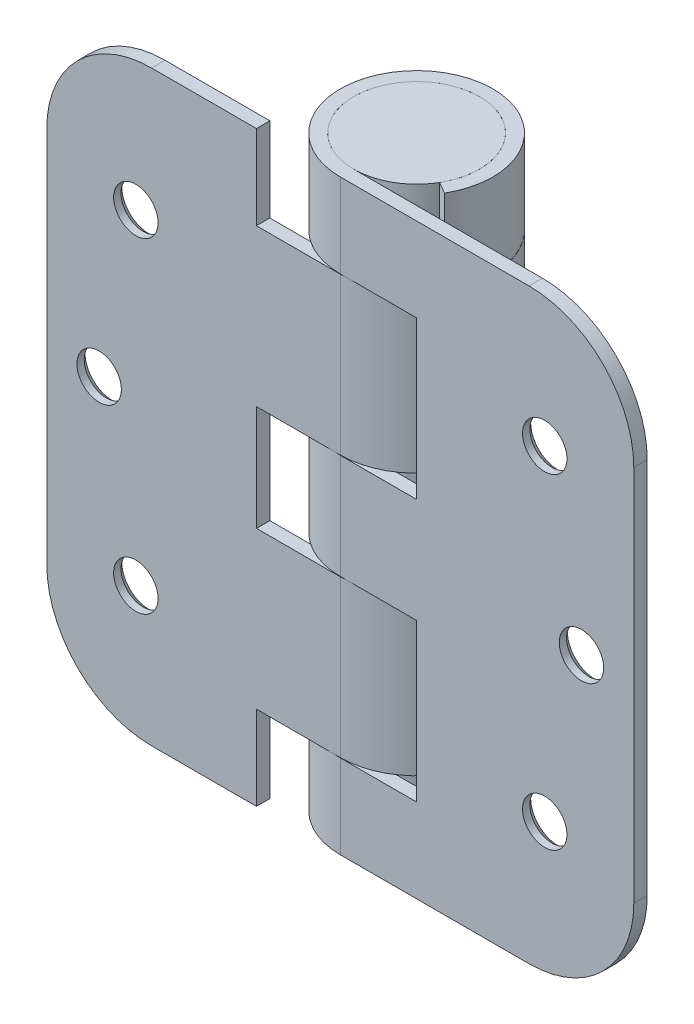
from build123d import *

# Parameters (mm, degrees)
EXTRUDE1_DEPTH                                = 44.45
CUT_EXTRUDE1_DEPTH                            = 22.082
CUT_EXTRUDE1_DEPTH_BACK                       = 3.032
EXTRUDE2_DEPTH                                = 11.85545
EXTRUDE2_DEPTH_BACK                           = 11.85545
EXTRUDE3_DEPTH                                = 11.85545
EXTRUDE3_DEPTH_BACK                           = 11.85545
EXTRUDE4_START                                = -24.60625
SKETCH5_W                                     = 31.75
SKETCH5_H                                     = 2.032
EXTRUDE4_DEPTH                                = 88.9
SKETCH6_W                                     = 9.525
SKETCH6_H                                     = 88.9
CSK_FOR_8_FLAT_HEAD_MACHINE_SCREW2_AT_2_COUNT = 2
CSK_FOR_8_FLAT_HEAD_MACHINE_SCREW2_AT_2_PITCH = 25.258138545
CSK_FOR_8_FLAT_HEAD_MACHINE_SCREW2_AT_3_COUNT = 2
CSK_FOR_8_FLAT_HEAD_MACHINE_SCREW2_AT_3_PITCH = 25.258138545
CSK_FOR_8_FLAT_HEAD_MACHINE_SCREW2_AT_4_COUNT = 2
CSK_FOR_8_FLAT_HEAD_MACHINE_SCREW2_AT_4_PITCH = 71.844514007
CSK_FOR_8_FLAT_HEAD_MACHINE_SCREW2_AT_5_COUNT = 2
CSK_FOR_8_FLAT_HEAD_MACHINE_SCREW2_AT_5_PITCH = 73.0504
CSK_FOR_8_FLAT_HEAD_MACHINE_SCREW2_AT_6_COUNT = 2
CSK_FOR_8_FLAT_HEAD_MACHINE_SCREW2_AT_6_PITCH = 71.844514007
FILLET1_R                                     = 15.875
FILLET2_R                                     = 15.875
FILLET3_R                                     = 15.875
FILLET4_R                                     = 15.875


with BuildPart() as part:
    # Sketch1 → Extrude1 (new body, symmetric)
    with BuildSketch(Plane(origin=(0, 0, 0), x_dir=(1, 0, 0), z_dir=(0, 1, 0))):
        with BuildLine():
            Line((0, -9.525), (44.45, -9.525))
            Line((44.45, -9.525), (44.45, -11.557))
            Line((44.45, -11.557), (0, -11.557))
            ThreePointArc((0, -11.557), (-5.7785, 10.008655592), (10.008655592, -5.7785))
            Line((10.008655592, -5.7785), (8.248891971, -4.7625))
            ThreePointArc((8.248891971, -4.7625), (-4.7625, 8.248891971), (0, -9.525))
        make_face()
    extrude(amount=EXTRUDE1_DEPTH, both=True)

    # Sketch2 → Cut-Extrude1 (cut, two sides)
    with BuildSketch(Plane(origin=(0, 0, 9.525), x_dir=(-1, 0, 0), z_dir=(0, 0, -1))) as cut_extrude1_sk:
        Polygon((11.557, 264.592751947), (11.557, 44.45), (11.557, 31.75), (-11.557, 31.75), (-11.557, 7.9375), (11.557, 7.9375), (11.557, -7.9375), (-11.557, -7.9375), (-11.557, -31.75), (11.557, -31.75), (11.557, -44.45), (11.557, -264.592751947), (451.842503895, -264.592751947), (451.842503895, 264.592751947), align=None)
    extrude(amount=CUT_EXTRUDE1_DEPTH, mode=Mode.SUBTRACT)
    extrude(cut_extrude1_sk.sketch, amount=-CUT_EXTRUDE1_DEPTH_BACK, mode=Mode.SUBTRACT)


with BuildPart() as body_2:
    # Sketch3 → Extrude2 (new body, two sides)
    with BuildSketch(Plane(origin=(0, 19.84375, 0), x_dir=(-1, 0, 0), z_dir=(0, 1, 0))) as extrude2_sk:
        with BuildLine():
            Line((44.45, 11.557), (44.45, 9.525))
            Line((44.45, 9.525), (0, 9.525))
            ThreePointArc((0, 9.525), (-4.7625, -8.248891971), (8.248891971, 4.7625))
            Line((8.248891971, 4.7625), (10.008655592, 5.7785))
            ThreePointArc((10.008655592, 5.7785), (-5.7785, -10.008655592), (0, 11.557))
            Line((0, 11.557), (44.45, 11.557))
        make_face()
    extrude(amount=EXTRUDE2_DEPTH)
    extrude(extrude2_sk.sketch, amount=-EXTRUDE2_DEPTH_BACK)



with BuildPart() as body_3:
    # Sketch4 → Extrude3 (new body, two sides)
    with BuildSketch(Plane(origin=(0, -19.84375, 0), x_dir=(-1, 0, 0), z_dir=(0, 1, 0))) as extrude3_sk:
        with BuildLine():
            Line((0, 9.525), (44.45, 9.525))
            Line((44.45, 9.525), (44.45, 11.557))
            Line((44.45, 11.557), (0, 11.557))
            ThreePointArc((0, 11.557), (-5.7785, -10.008655592), (10.008655592, 5.7785))
            Line((10.008655592, 5.7785), (8.248891971, 4.7625))
            ThreePointArc((8.248891971, 4.7625), (-4.7625, -8.248891971), (0, 9.525))
        make_face()
    extrude(amount=EXTRUDE3_DEPTH)
    extrude(extrude3_sk.sketch, amount=-EXTRUDE3_DEPTH_BACK)


with BuildPart() as body_2_1:
    add(body_2.part)

    add(body_3.part)  # Extrude4 merges body 3
    # Sketch5 → Extrude4 (add)
    with BuildSketch(Plane(origin=(0, -19.84375, 0), x_dir=(-1, 0, 0), z_dir=(0, 1, 0)).offset(EXTRUDE4_START)):
        with Locations((28.575, 10.541)):
            Rectangle(SKETCH5_W, SKETCH5_H)
    extrude(amount=EXTRUDE4_DEPTH)

    # Sketch9 → CSK for #8 Flat Head Machine Screw2 (revolve, cut)
    with BuildSketch(Plane(origin=(-36.5252, 0, 9.525), x_dir=(0, 1, 0), z_dir=(1, 0, 0))):
        Polygon((0, 0), (0, 4.130193213), (3.3655, 2.1079968), (3.3655, 0.920409763), (4.1656, 0), align=None)
    csk_for_8_flat_head_machine_screw2 = revolve(axis=Axis((-36.5252, 0, 3.175), (0, 0, 1)), mode=Mode.SUBTRACT)

    # CSK for #8 Flat Head Machine Screw2 at 2: CSK for #8 Flat Head Machine Screw2 ×2
    with Locations(*[Vector(0.220230006, 0.975447971, 0) * (i * CSK_FOR_8_FLAT_HEAD_MACHINE_SCREW2_AT_2_PITCH) for i in range(1, CSK_FOR_8_FLAT_HEAD_MACHINE_SCREW2_AT_2_COUNT)]):
        add(csk_for_8_flat_head_machine_screw2, mode=Mode.SUBTRACT)

    # CSK for #8 Flat Head Machine Screw2 at 3: CSK for #8 Flat Head Machine Screw2 ×2
    with Locations(*[Vector(0.220230006, -0.975447971, 0) * (i * CSK_FOR_8_FLAT_HEAD_MACHINE_SCREW2_AT_3_PITCH) for i in range(1, CSK_FOR_8_FLAT_HEAD_MACHINE_SCREW2_AT_3_COUNT)]):
        add(csk_for_8_flat_head_machine_screw2, mode=Mode.SUBTRACT)

    # Fillet3
    fillet3_edges = [body_2_1.edges().sort_by_distance(p)[0] for p in [
        (-44.45, 44.45, 10.541),
    ]]
    fillet(fillet3_edges, radius=FILLET3_R)

    # Fillet4
    fillet4_edges = [body_2_1.edges().sort_by_distance(p)[0] for p in [
        (-44.45, -44.45, 10.541),
    ]]
    fillet(fillet4_edges, radius=FILLET4_R)


with BuildPart() as body_3_2:
    # Sketch6 → Revolve1 (revolve)
    with BuildSketch(Plane.XY):
        with Locations((-4.7625, 0)):
            Rectangle(SKETCH6_W, SKETCH6_H)
    revolve(axis=Axis((0, 42.361566849, 0), (0, -1, 0)))


with BuildPart() as part_1:
    add(part.part)

    # CSK for #8 Flat Head Machine Screw2 at 4: CSK for #8 Flat Head Machine Screw2 ×2
    with Locations(*[Vector(0.939359128, -0.342935022, 0) * (i * CSK_FOR_8_FLAT_HEAD_MACHINE_SCREW2_AT_4_PITCH) for i in range(1, CSK_FOR_8_FLAT_HEAD_MACHINE_SCREW2_AT_4_COUNT)]):
        add(csk_for_8_flat_head_machine_screw2, mode=Mode.SUBTRACT)

    # CSK for #8 Flat Head Machine Screw2 at 5: CSK for #8 Flat Head Machine Screw2 ×2
    with Locations(*[(i * CSK_FOR_8_FLAT_HEAD_MACHINE_SCREW2_AT_5_PITCH, 0, 0) for i in range(1, CSK_FOR_8_FLAT_HEAD_MACHINE_SCREW2_AT_5_COUNT)]):
        add(csk_for_8_flat_head_machine_screw2, mode=Mode.SUBTRACT)

    # CSK for #8 Flat Head Machine Screw2 at 6: CSK for #8 Flat Head Machine Screw2 ×2
    with Locations(*[Vector(0.939359128, 0.342935022, 0) * (i * CSK_FOR_8_FLAT_HEAD_MACHINE_SCREW2_AT_6_PITCH) for i in range(1, CSK_FOR_8_FLAT_HEAD_MACHINE_SCREW2_AT_6_COUNT)]):
        add(csk_for_8_flat_head_machine_screw2, mode=Mode.SUBTRACT)

    # Fillet1
    fillet1_edges = [part_1.edges().sort_by_distance(p)[0] for p in [
        (44.45, 44.45, 10.541),
    ]]
    fillet(fillet1_edges, radius=FILLET1_R)

    # Fillet2
    fillet2_edges = [part_1.edges().sort_by_distance(p)[0] for p in [
        (44.45, -44.45, 10.541),
    ]]
    fillet(fillet2_edges, radius=FILLET2_R)


solid = Compound([body_2_1.part, body_3_2.part, part_1.part])
